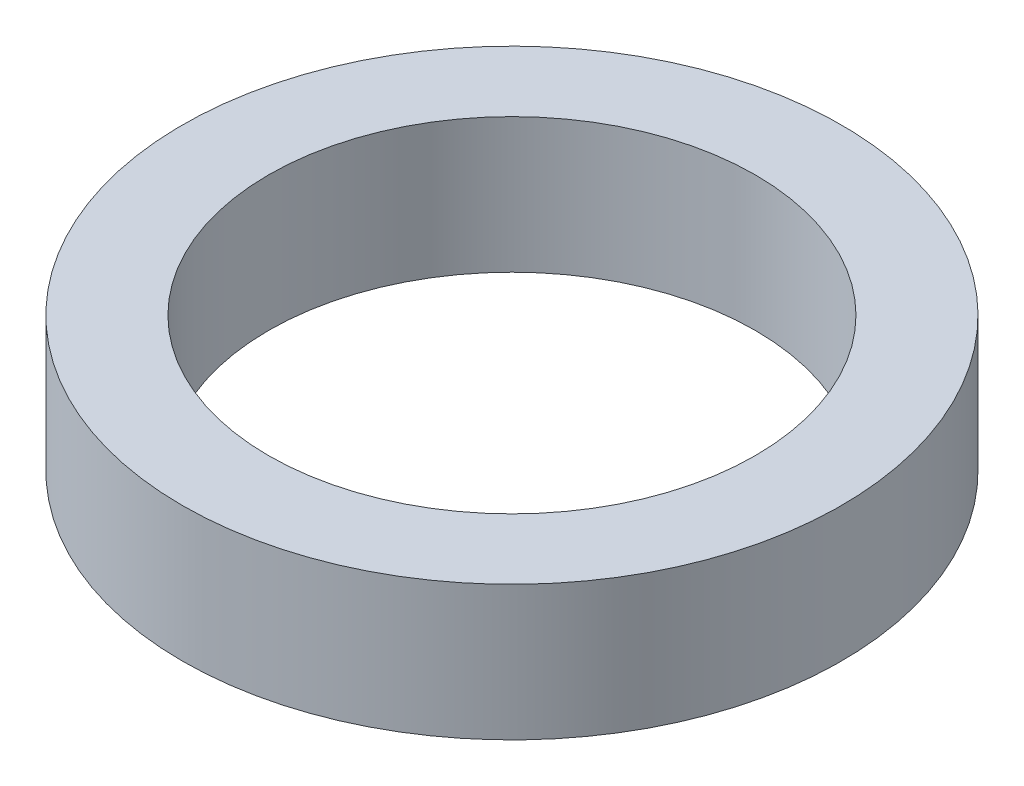
from build123d import *

# Parameters (mm, degrees)
SKETCH1_R           = 13.97
SKETCH1_R_2         = 10.3124
BOSS_EXTRUDE1_DEPTH = 5.71246


with BuildPart() as part:
    # Sketch1 → Boss-Extrude1 (new body)
    with BuildSketch(Plane(origin=(0, 0, 0), x_dir=(1, 0, 0), z_dir=(0, 1, 0))):
        Circle(SKETCH1_R)
        Circle(SKETCH1_R_2, mode=Mode.SUBTRACT)
    extrude(amount=BOSS_EXTRUDE1_DEPTH)


solid = part.part
